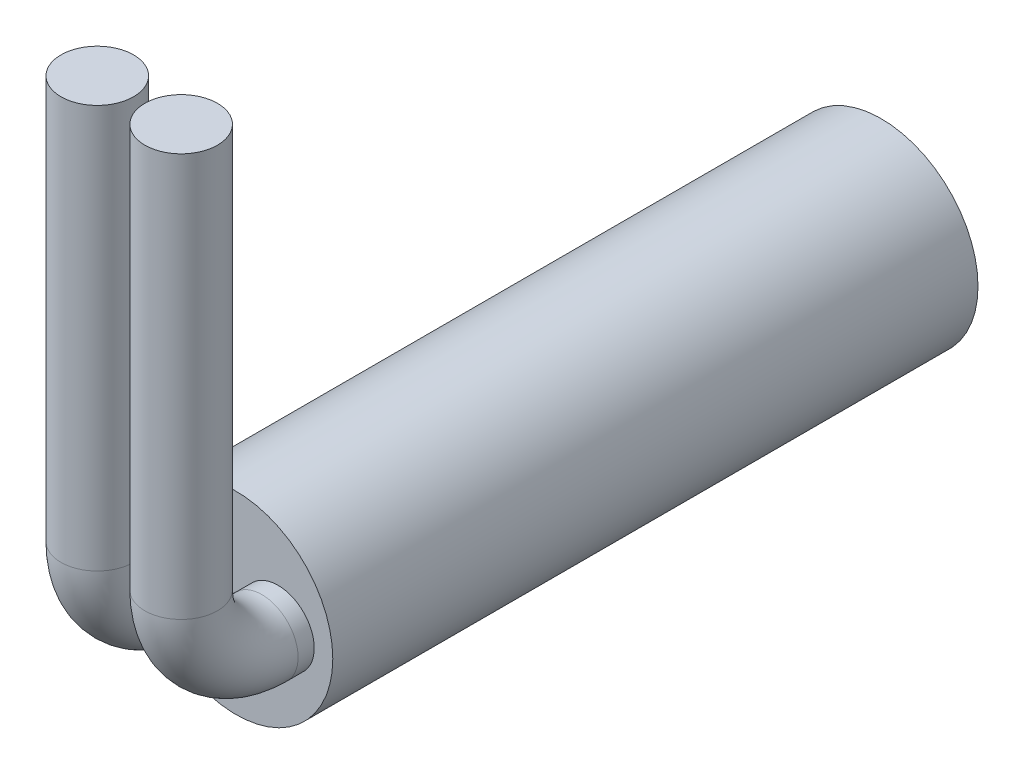
from build123d import *

# Parameters (mm, degrees)
SKETCH4_R           = 3
BOSS_EXTRUDE1_DEPTH = 20
SKETCH5_R           = 1.125
SKETCH10_R          = 1.125


with BuildPart() as part:
    # Sketch4 → Boss-Extrude1 (new body)
    with BuildSketch(Plane.XY):
        Circle(SKETCH4_R)
    extrude(amount=-BOSS_EXTRUDE1_DEPTH)


with BuildPart() as body_2:
    # Sweep2: sweep along a path in Sketch9
    with BuildLine(Plane.ZY.offset(2.55)) as sweep2_path:
        Line((3, 15), (3, 2.5))
        ThreePointArc((3, 2.5), (2.267766953, 0.732233047), (0.5, 0))
        Line((0.5, 0), (0, 0))
    # Sketch5 → Sweep2 (sweep)
    with BuildSketch(Plane.XY):
        with Locations((-1.3, 0)):
            Circle(SKETCH5_R)
    sweep(path=sweep2_path.line)


with BuildPart() as body_3:
    # Sweep3: sweep along a path in Sketch15
    with BuildLine(Plane.ZY.offset(-0.05)) as sweep3_path:
        Line((3, 15), (3, 2.5))
        ThreePointArc((3, 2.5), (2.267766953, 0.732233047), (0.5, 0))
        Line((0.5, 0), (0, 0))
    # Sketch10 → Sweep3 (sweep)
    with BuildSketch(Plane.XY):
        with Locations((1.3, 0)):
            Circle(SKETCH10_R)
    sweep(path=sweep3_path.line)


solid = Compound([part.part, body_2.part, body_3.part])
